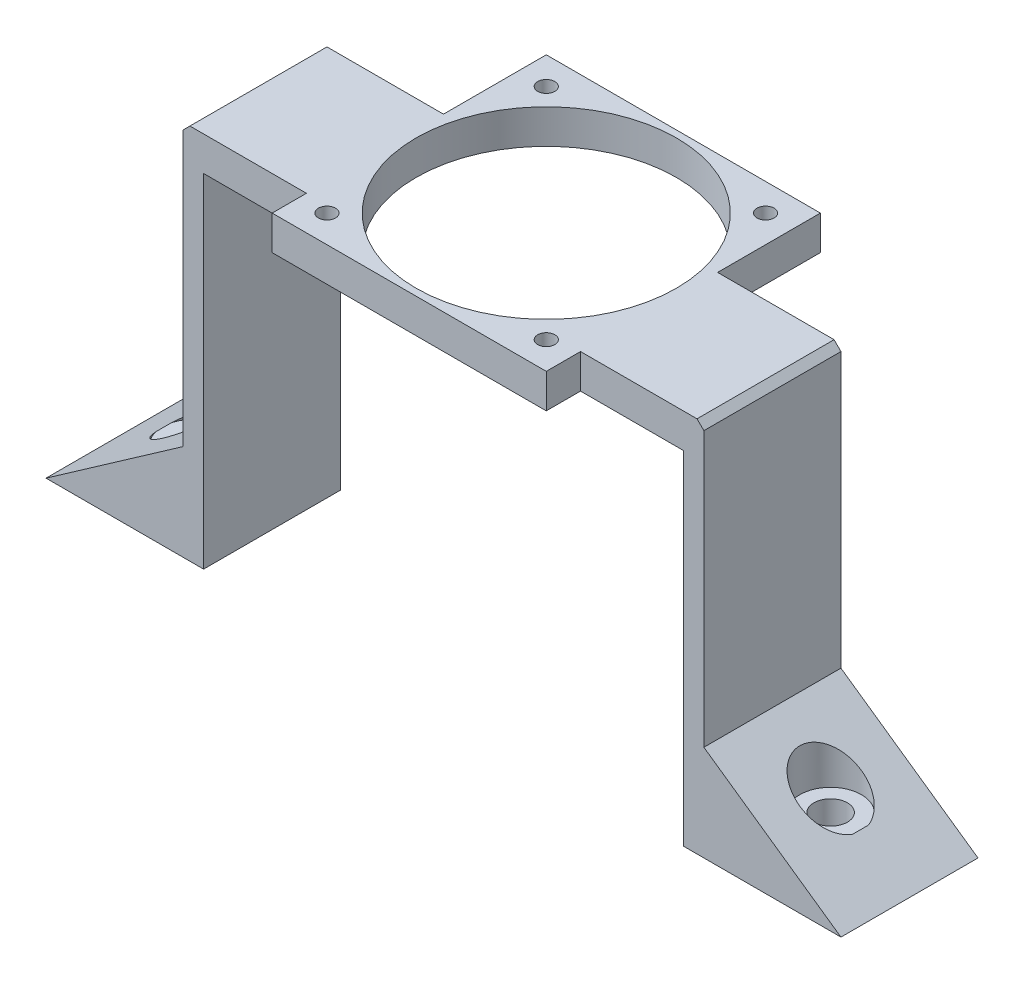
from build123d import *

# Parameters (mm, degrees)
EXTRUDE_1_DEPTH     = 20
SKETCH_2_W          = 40
SKETCH_2_H          = 40
EXTRUDE_3_DEPTH     = 3
SKETCH_3_R          = 19
CUT_EXTRUDE_1_DEPTH = 3
SKETCH_4_R          = 1.25
CUT_EXTRUDE_2_DEPTH = 3
SKETCH_5_R          = 19
EXTRUDE_4_DEPTH     = 2
SKETCH_6_R          = 1.25
CUT_EXTRUDE_3_DEPTH = 2
EXTRUDE_5_DEPTH     = 20
CUT_EXTRUDE_4_DEPTH = 59
SKETCH_11_R         = 2.45
CUT_EXTRUDE_5_DEPTH = 59
SKETCH_12_R         = 4.5
CUT_EXTRUDE_6_DEPTH = 59
CHAMFER_1_SIZE      = 1


with BuildPart() as part:
    # 草图1 → 凸台-拉伸1 (new body)
    with BuildSketch(Plane.XY):
        Polygon((-33.585585586, 27.988738739), (-33.585585586, -25.011261261), (-30.585585586, -25.011261261), (-30.585585586, 24.988738739), (39.414414414, 24.988738739), (39.414414414, -25.011261261), (42.414414414, -25.011261261), (42.414414414, 27.988738739), align=None)
    extrude(amount=EXTRUDE_1_DEPTH)

    # 草图2 → 凸台-拉伸3 (add)
    with BuildSketch(Plane(origin=(0, 27.988738739, 0), x_dir=(1, 0, 0), z_dir=(0, 1, 0))):
        with Locations((4.414414414, -5)):
            Rectangle(SKETCH_2_W, SKETCH_2_H)
    extrude(amount=-EXTRUDE_3_DEPTH)

    # 草图3 → 切除-拉伸1 (cut)
    with BuildSketch(Plane(origin=(0, 27.988738739, 0), x_dir=(1, 0, 0), z_dir=(0, 1, 0))):
        with Locations((4.414414414, -5)):
            Circle(SKETCH_3_R)
    extrude(amount=-CUT_EXTRUDE_1_DEPTH, mode=Mode.SUBTRACT)

    # 草图4 → 切除-拉伸2 (cut)
    with BuildSketch(Plane(origin=(0, 27.988738739, 0), x_dir=(1, 0, 0), z_dir=(0, 1, 0))):
        with Locations((20.414414414, 11)):
            Circle(SKETCH_4_R)
        with Locations((20.414414414, -21)):
            Circle(SKETCH_4_R)
        with Locations((-11.585585586, -21)):
            Circle(SKETCH_4_R)
        with Locations((-11.585585586, 11)):
            Circle(SKETCH_4_R)
    extrude(amount=-CUT_EXTRUDE_2_DEPTH, mode=Mode.SUBTRACT)

    # 草图5 → 凸台-拉伸4 (add)
    with BuildSketch(Plane(origin=(0, 27.988738739, 0), x_dir=(1, 0, 0), z_dir=(0, 1, 0))):
        Polygon((-33.585585586, -20), (-15.585585586, -20), (-15.585585586, -25), (24.414414414, -25), (24.414414414, -20), (42.414414414, -20), (42.414414414, 0), (24.414414414, 0), (24.414414414, 15), (-15.585585586, 15), (-15.585585586, 0), (-33.585585586, 0), align=None)
        with Locations((4.414414414, -5)):
            Circle(SKETCH_5_R, mode=Mode.SUBTRACT)
    extrude(amount=EXTRUDE_4_DEPTH)

    # 草图6 → 切除-拉伸3 (cut)
    with BuildSketch(Plane.XZ.offset(-27.988738739)):
        with Locations((20.414414414, 21)):
            Circle(SKETCH_6_R)
        with Locations((20.414414414, -11)):
            Circle(SKETCH_6_R)
        with Locations((-11.585585586, -11)):
            Circle(SKETCH_6_R)
        with Locations((-11.585585586, 21)):
            Circle(SKETCH_6_R)
    extrude(amount=-CUT_EXTRUDE_3_DEPTH, mode=Mode.SUBTRACT)

    # 草图7 → 凸台-拉伸5 (add)
    with BuildSketch(Plane(origin=(0, 0, 0), x_dir=(-1, 0, 0), z_dir=(0, 0, -1))):
        Polygon((33.585585586, -25.011261261), (53.585585586, -25.011261261), (33.585585586, -11.021791252), align=None)
    extrude(amount=-EXTRUDE_5_DEPTH)

    # 草图10 → 切除-拉伸4 (cut)
    with BuildSketch(Plane(origin=(0, 0, -15), x_dir=(-1, 0, 0), z_dir=(0, 0, -1))):
        Polygon((-4.414414414, 24.988738739), (-4.414414414, -56.650285004), (-57.489425736, -56.650285004), (-57.489425736, 45.664413948), (-4.414414414, 45.664413948), align=None)
    extrude(amount=-CUT_EXTRUDE_4_DEPTH, mode=Mode.SUBTRACT)

    # 草图11 → 切除-拉伸5 (cut)
    with BuildSketch(Plane.XZ.offset(25.011261261)):
        with Locations((-42.085585586, 10)):
            Circle(SKETCH_11_R)
    extrude(amount=-CUT_EXTRUDE_5_DEPTH, mode=Mode.SUBTRACT)

    # 草图12 → 切除-拉伸6 (cut)
    with BuildSketch(Plane(origin=(0, -20.011261261, 0), x_dir=(-1, 0, 0), z_dir=(0, -1, 0))):
        with Locations((42.085585586, -10)):
            Circle(SKETCH_12_R)
    extrude(amount=-CUT_EXTRUDE_6_DEPTH, mode=Mode.SUBTRACT)

    # 镜向2: part across plane


with BuildPart() as part_1:
    add(part.part)
    add(part.part.mirror(Plane(origin=(4.414414414, 24.988738739, 44), x_dir=(0, 0, 1), z_dir=(-1, 0, 0))))

    # 倒角1
    chamfer_1_edges = [part_1.edges().sort_by_distance(p)[0] for p in [
        (42.414414414, 29.988738739, 10),
        (-33.585585586, 29.988738739, 10),
    ]]
    chamfer(chamfer_1_edges, length=CHAMFER_1_SIZE)


solid = part_1.part
